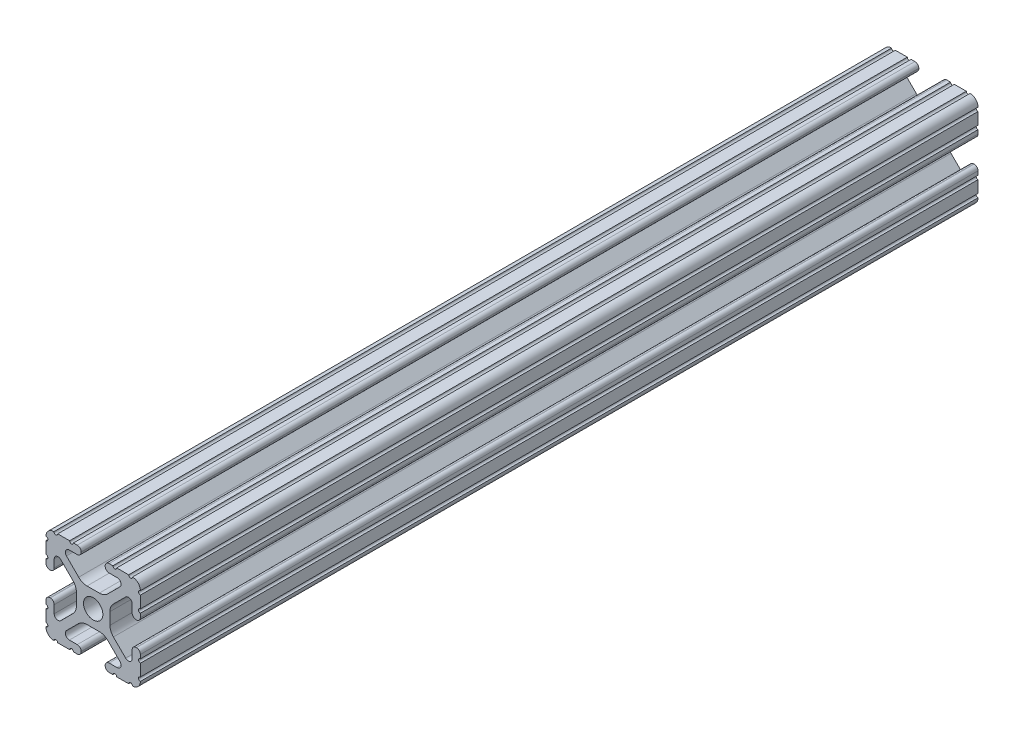
from build123d import *

# Parameters (mm, degrees)
SKETCH1_R               = 2.6035
BOSS_EXTRUDE1_DEPTH     = 609.6
SKETCH2_W               = 52.583844564
SKETCH2_H               = 999.926982924
CUT_EXTRUDE1_DEPTH      = 21.082
CUT_EXTRUDE1_DEPTH_BACK = 22.352


with BuildPart() as part:
    # Sketch1 → Boss-Extrude1 (new body, symmetric)
    with BuildSketch(Plane.XY):
        with BuildLine():
            Line((-7.179650497, -8.645192506), (-3.952270251, -5.423690499))
            ThreePointArc((-3.952270251, -5.423690499), (-2.922936451, -4.736929036), (-1.709253557, -4.4958))
            Line((-1.709253557, -4.4958), (1.709253557, -4.4958))
            ThreePointArc((1.709253557, -4.4958), (2.922936451, -4.736929036), (3.952270251, -5.423690499))
            Line((3.952270251, -5.423690499), (7.179650497, -8.645192506))
            ThreePointArc((7.179650497, -8.645192506), (7.41473083, -9.822813117), (6.416408329, -10.4902))
            Line((6.416408329, -10.4902), (4.287512407, -10.4902))
            ThreePointArc((4.287512407, -10.4902), (3.54574862, -10.79744862), (3.2385, -11.539212407))
            Line((3.2385, -11.539212407), (3.2385, -11.650987593))
            ThreePointArc((3.2385, -11.650987593), (3.54574862, -12.39275138), (4.287512407, -12.7))
            Line((4.287512407, -12.7), (5.317126718, -12.7))
            ThreePointArc((5.317126718, -12.7), (5.825126718, -12.192), (6.333126718, -12.7))
            Line((6.333126718, -12.7), (9.550443118, -12.7))
            ThreePointArc((9.550443118, -12.7), (10.058366869, -12.192000006), (10.566443095, -12.699847501))
            ThreePointArc((10.566443095, -12.699847501), (12.082537762, -12.08250727), (12.699846982, -10.566399977))
            ThreePointArc((12.699846982, -10.566399977), (12.192000006, -10.058323491), (12.7, -9.5504))
            Line((12.7, -9.5504), (12.7, -6.3330836))
            ThreePointArc((12.7, -6.3330836), (12.192, -5.8250836), (12.7, -5.3170836))
            Line((12.7, -5.3170836), (12.7, -4.287469289))
            ThreePointArc((12.7, -4.287469289), (12.39275138, -3.545705502), (11.650987593, -3.238456882))
            Line((11.650987593, -3.238456882), (11.539212407, -3.238456882))
            ThreePointArc((11.539212407, -3.238456882), (10.79744862, -3.545705502), (10.4902, -4.287469289))
            Line((10.4902, -4.287469289), (10.4902, -6.402089023))
            ThreePointArc((10.4902, -6.402089023), (9.856505071, -7.351067942), (8.737131347, -7.129408934))
            Line((8.737131347, -7.129408934), (5.441005833, -3.840816462))
            ThreePointArc((5.441005833, -3.840816462), (4.750877967, -2.809883091), (4.5085, -1.593185507))
            Line((4.5085, -1.593185507), (4.5085, 1.593185507))
            ThreePointArc((4.5085, 1.593185507), (4.750877967, 2.809883091), (5.441005833, 3.840816462))
            Line((5.441005833, 3.840816462), (8.737131347, 7.129408934))
            ThreePointArc((8.737131347, 7.129408934), (9.856505071, 7.351067942), (10.4902, 6.402089023))
            Line((10.4902, 6.402089023), (10.4902, 4.287469289))
            ThreePointArc((10.4902, 4.287469289), (10.79744862, 3.545705502), (11.539212407, 3.238456882))
            Line((11.539212407, 3.238456882), (11.650987593, 3.238456882))
            ThreePointArc((11.650987593, 3.238456882), (12.39275138, 3.545705502), (12.7, 4.287469289))
            Line((12.7, 4.287469289), (12.7, 5.3170836))
            ThreePointArc((12.7, 5.3170836), (12.192, 5.8250836), (12.7, 6.3330836))
            Line((12.7, 6.3330836), (12.7, 9.5504))
            ThreePointArc((12.7, 9.5504), (12.192000006, 10.058323491), (12.699846982, 10.566399977))
            ThreePointArc((12.699846982, 10.566399977), (12.082537762, 12.08250727), (10.566443095, 12.699847501))
            ThreePointArc((10.566443095, 12.699847501), (10.058366869, 12.192000006), (9.550443118, 12.7))
            Line((9.550443118, 12.7), (6.333126718, 12.7))
            ThreePointArc((6.333126718, 12.7), (5.825126718, 12.192), (5.317126718, 12.7))
            Line((5.317126718, 12.7), (4.287512407, 12.7))
            ThreePointArc((4.287512407, 12.7), (3.54574862, 12.39275138), (3.2385, 11.650987593))
            Line((3.2385, 11.650987593), (3.2385, 11.539212407))
            ThreePointArc((3.2385, 11.539212407), (3.54574862, 10.79744862), (4.287512407, 10.4902))
            Line((4.287512407, 10.4902), (6.476788598, 10.4902))
            ThreePointArc((6.476788598, 10.4902), (7.432222385, 9.85140422), (7.207036008, 8.724370562))
            Line((7.207036008, 8.724370562), (3.898272566, 5.423169045))
            ThreePointArc((3.898272566, 5.423169045), (2.869120213, 4.736787962), (1.655778399, 4.4958))
            Line((1.655778399, 4.4958), (-1.655778399, 4.4958))
            ThreePointArc((-1.655778399, 4.4958), (-2.869120213, 4.736787962), (-3.898272566, 5.423169045))
            Line((-3.898272566, 5.423169045), (-7.207036008, 8.724370562))
            ThreePointArc((-7.207036008, 8.724370562), (-7.432222385, 9.85140422), (-6.476788598, 10.4902))
            Line((-6.476788598, 10.4902), (-4.287512407, 10.4902))
            ThreePointArc((-4.287512407, 10.4902), (-3.54574862, 10.79744862), (-3.2385, 11.539212407))
            Line((-3.2385, 11.539212407), (-3.2385, 11.650987593))
            ThreePointArc((-3.2385, 11.650987593), (-3.54574862, 12.39275138), (-4.287512407, 12.7))
            Line((-4.287512407, 12.7), (-5.317126718, 12.7))
            ThreePointArc((-5.317126718, 12.7), (-5.825126718, 12.192), (-6.333126718, 12.7))
            Line((-6.333126718, 12.7), (-9.550443118, 12.7))
            ThreePointArc((-9.550443118, 12.7), (-10.058366869, 12.192000006), (-10.566443095, 12.699847501))
            ThreePointArc((-10.566443095, 12.699847501), (-12.082537762, 12.08250727), (-12.699846982, 10.566399977))
            ThreePointArc((-12.699846982, 10.566399977), (-12.192000006, 10.058323491), (-12.7, 9.5504))
            Line((-12.7, 9.5504), (-12.7, 6.3330836))
            ThreePointArc((-12.7, 6.3330836), (-12.192, 5.8250836), (-12.7, 5.3170836))
            Line((-12.7, 5.3170836), (-12.7, 4.287469289))
            ThreePointArc((-12.7, 4.287469289), (-12.39275138, 3.545705502), (-11.650987593, 3.238456882))
            Line((-11.650987593, 3.238456882), (-11.539212407, 3.238456882))
            ThreePointArc((-11.539212407, 3.238456882), (-10.79744862, 3.545705502), (-10.4902, 4.287469289))
            Line((-10.4902, 4.287469289), (-10.4902, 6.402089023))
            ThreePointArc((-10.4902, 6.402089023), (-9.856505071, 7.351067942), (-8.737131347, 7.129408934))
            Line((-8.737131347, 7.129408934), (-5.441005833, 3.840816462))
            ThreePointArc((-5.441005833, 3.840816462), (-4.750877967, 2.809883091), (-4.5085, 1.593185507))
            Line((-4.5085, 1.593185507), (-4.5085, -1.593185507))
            ThreePointArc((-4.5085, -1.593185507), (-4.750877967, -2.809883091), (-5.441005833, -3.840816462))
            Line((-5.441005833, -3.840816462), (-8.737131347, -7.129408934))
            ThreePointArc((-8.737131347, -7.129408934), (-9.856505071, -7.351067942), (-10.4902, -6.402089023))
            Line((-10.4902, -6.402089023), (-10.4902, -4.287469289))
            ThreePointArc((-10.4902, -4.287469289), (-10.79744862, -3.545705502), (-11.539212407, -3.238456882))
            Line((-11.539212407, -3.238456882), (-11.650987593, -3.238456882))
            ThreePointArc((-11.650987593, -3.238456882), (-12.39275138, -3.545705502), (-12.7, -4.287469289))
            Line((-12.7, -4.287469289), (-12.7, -5.3170836))
            ThreePointArc((-12.7, -5.3170836), (-12.192, -5.8250836), (-12.7, -6.3330836))
            Line((-12.7, -6.3330836), (-12.7, -9.5504))
            ThreePointArc((-12.7, -9.5504), (-12.192000006, -10.058323491), (-12.699846982, -10.566399977))
            ThreePointArc((-12.699846982, -10.566399977), (-12.082537762, -12.08250727), (-10.566443095, -12.699847501))
            ThreePointArc((-10.566443095, -12.699847501), (-10.058366869, -12.192000006), (-9.550443118, -12.7))
            Line((-9.550443118, -12.7), (-6.333126718, -12.7))
            ThreePointArc((-6.333126718, -12.7), (-5.825126718, -12.192), (-5.317126718, -12.7))
            Line((-5.317126718, -12.7), (-4.287512407, -12.7))
            ThreePointArc((-4.287512407, -12.7), (-3.54574862, -12.39275138), (-3.2385, -11.650987593))
            Line((-3.2385, -11.650987593), (-3.2385, -11.539212407))
            ThreePointArc((-3.2385, -11.539212407), (-3.54574862, -10.79744862), (-4.287512407, -10.4902))
            Line((-4.287512407, -10.4902), (-6.416408329, -10.4902))
            ThreePointArc((-6.416408329, -10.4902), (-7.41473083, -9.822813117), (-7.179650497, -8.645192506))
        make_face()
        Circle(SKETCH1_R, mode=Mode.SUBTRACT)
    extrude(amount=BOSS_EXTRUDE1_DEPTH, both=True)

    # Sketch2 → Cut-Extrude1 (cut, two sides)
    with BuildSketch(Plane(origin=(-0.793875106, -0.795693603, 0), x_dir=(0.707915262, -0.706297375, 0), z_dir=(-0.706297375, -0.707915262, 0))) as cut_extrude1_sk:
        with Locations((4.622489738, -115.840698227)):
            Rectangle(SKETCH2_W, SKETCH2_H)
    extrude(amount=CUT_EXTRUDE1_DEPTH, mode=Mode.SUBTRACT)
    extrude(cut_extrude1_sk.sketch, amount=-CUT_EXTRUDE1_DEPTH_BACK, mode=Mode.SUBTRACT)


solid = part.part
